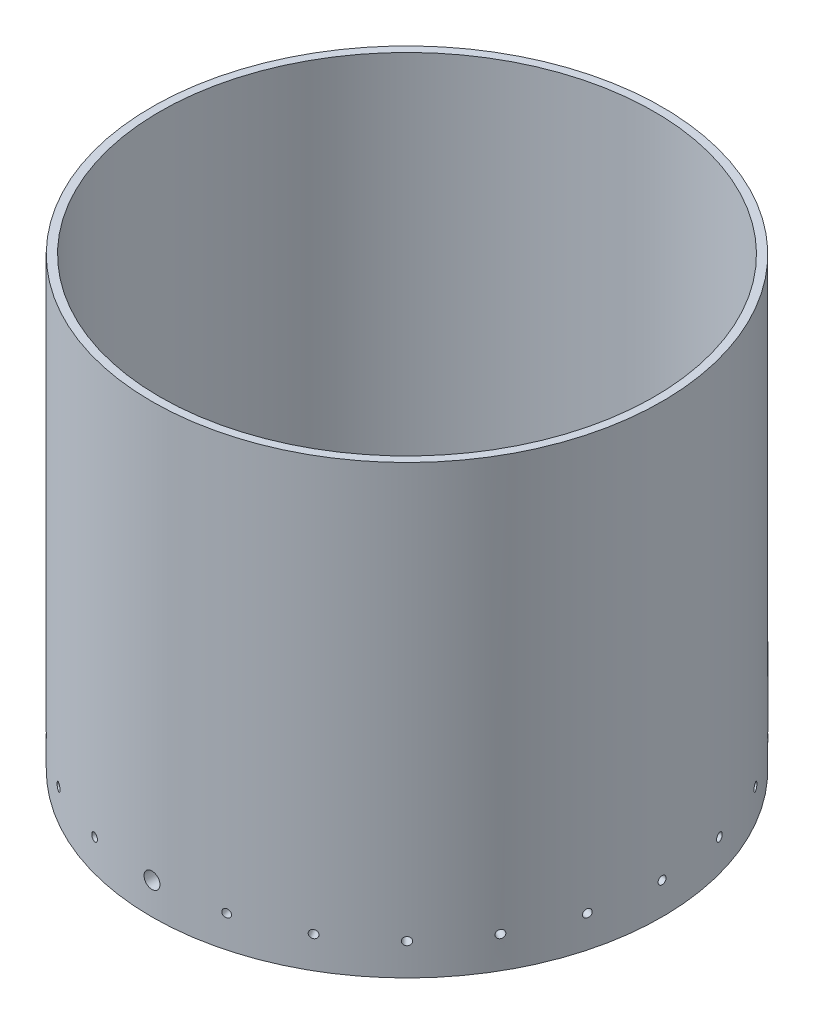
from build123d import *

# Parameters (mm, degrees)
SKETCH1_R               = 101.6
SKETCH1_R_2             = 95.25
BOSS_EXTRUDE1_DEPTH     = 25.4
SKETCH2_R               = 3.175
CUT_EXTRUDE1_DEPTH      = 102.6
CUT_EXTRUDE1_DEPTH_BACK = 102.6
SKETCH3_R               = 1.5875
CUT_EXTRUDE3_DEPTH      = 102.6000001
CIRPATTERN1_COUNT       = 24
SKETCH5_R               = 101.6
SKETCH5_R_2             = 98.425
BOSS_EXTRUDE2_DEPTH     = 152.4


with BuildPart() as part:
    # Sketch1 → Boss-Extrude1 (new body)
    with BuildSketch(Plane(origin=(0, 0, 0), x_dir=(1, 0, 0), z_dir=(0, 1, 0))):
        Circle(SKETCH1_R)
        Circle(SKETCH1_R_2, mode=Mode.SUBTRACT)
    extrude(amount=BOSS_EXTRUDE1_DEPTH)

    # Sketch2 → Cut-Extrude1 (cut, two sides)
    with BuildSketch(Plane.XY) as cut_extrude1_sk:
        with Locations((0, 12.7)):
            Circle(SKETCH2_R)
    extrude(amount=CUT_EXTRUDE1_DEPTH, mode=Mode.SUBTRACT)
    extrude(cut_extrude1_sk.sketch, amount=-CUT_EXTRUDE1_DEPTH_BACK, mode=Mode.SUBTRACT)

    # Sketch3 → Cut-Extrude3 (cut, through all)
    with BuildSketch(Plane(origin=(0, 0, 0), x_dir=(0, 0, -1), z_dir=(1, 0, 0))):
        with Locations((0, 12.7)):
            Circle(SKETCH3_R)
    cut_extrude3 = extrude(amount=-CUT_EXTRUDE3_DEPTH, mode=Mode.SUBTRACT)

    # CirPattern1: Cut-Extrude3 ×24 about axis
    cirpattern1_axis = Axis((0, 0, 0), (0, 1, 0))
    for i in range(1, CIRPATTERN1_COUNT):
        add(cut_extrude3.rotate(cirpattern1_axis, i * 360 / CIRPATTERN1_COUNT), mode=Mode.SUBTRACT)

    # Sketch5 → Boss-Extrude2 (add)
    with BuildSketch(Plane(origin=(0, 25.4, 0), x_dir=(1, 0, 0), z_dir=(0, 1, 0))):
        Circle(SKETCH5_R)
        Circle(SKETCH5_R_2, mode=Mode.SUBTRACT)
    extrude(amount=BOSS_EXTRUDE2_DEPTH)


solid = part.part
